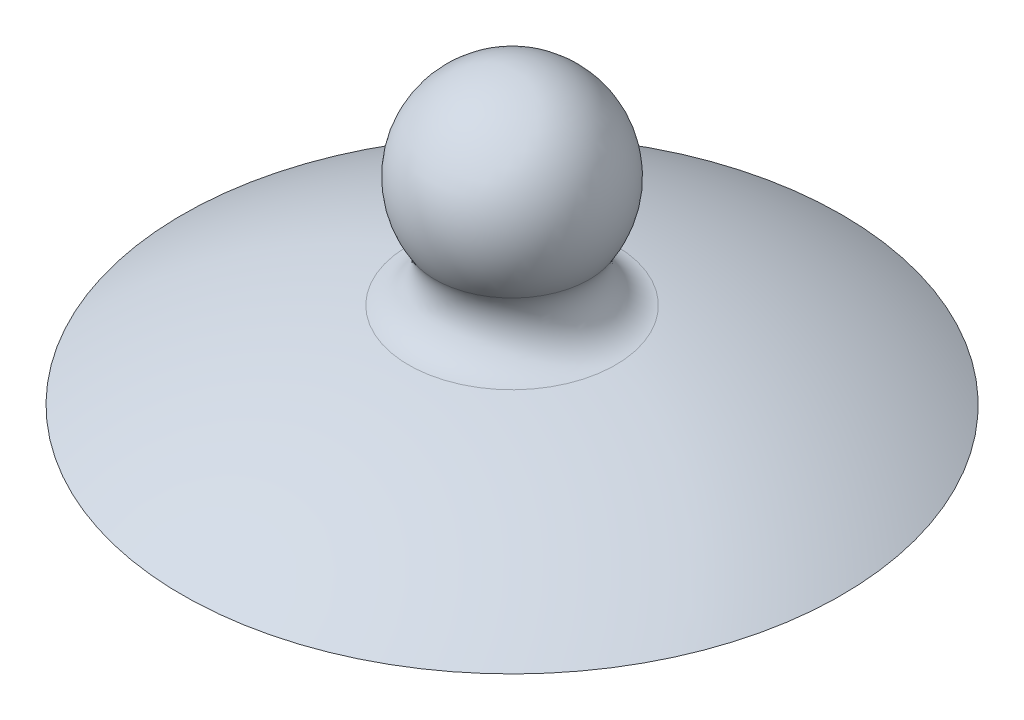
from build123d import *


with BuildPart() as part:
    # Sketch1 → Revolve1 (revolve)
    with BuildSketch(Plane.XY):
        with BuildLine():
            Line((0, 22), (0, 0))
            Line((0, 0), (17.5, 0))
            Line((17.5, 0), (17.5, -3))
            Line((17.5, -3), (20.5, -3))
            Line((20.5, -3), (20.5, 0))
            Line((20.5, 0), (25, 0))
            ThreePointArc((25, 0), (16.747123528, 4.115577986), (7.849471791, 6.540396696))
            ThreePointArc((7.849471791, 6.540396696), (5.599395212, 8.301845982), (5.845351334, 11.148783597))
            ThreePointArc((5.845351334, 11.148783597), (6.162731327, 18.319750381), (0, 22))
        make_face()
    revolve(axis=Axis((0, 0, 0), (0, 1, 0)))


solid = part.part
